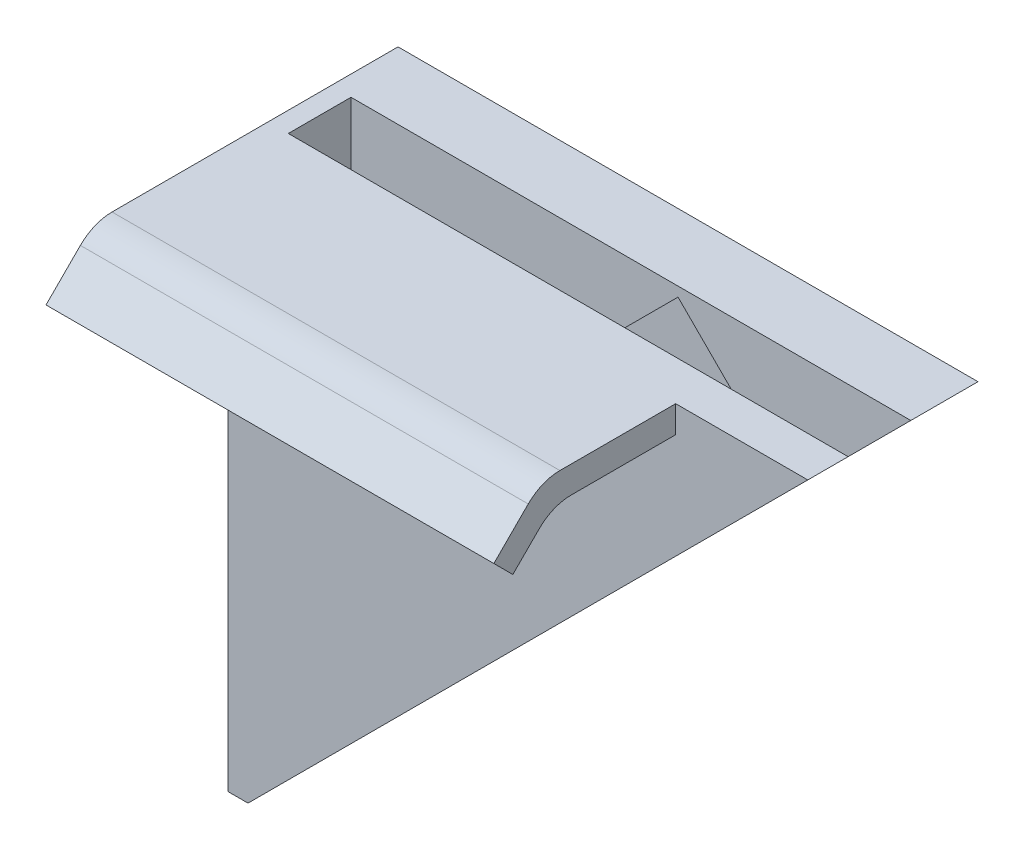
from build123d import *

# Parameters (mm, degrees)
SALIENTE_EXTRUIR1_DEPTH = 1.8
CROQUIS2_W              = 7.6
CROQUIS2_H              = 25
SALIENTE_EXTRUIR2_DEPTH = 0.9
SALIENTE_EXTRUIR3_DEPTH = 3
CORTAR_EXTRUIR1_DEPTH   = 2.05
SALIENTE_EXTRUIR4_DEPTH = 20
REDONDEO1_R             = 2


with BuildPart() as part:
    # Croquis1 → Saliente-Extruir1 (new body)
    with BuildSketch(Plane.XY):
        Polygon((0, 0), (25, 0), (0, -25), align=None)
    extrude(amount=SALIENTE_EXTRUIR1_DEPTH)

    # Croquis2 → Saliente-Extruir2 (add)
    with BuildSketch(Plane.ZY):
        with Locations((-2, -12.5)):
            Rectangle(CROQUIS2_W, CROQUIS2_H)
    extrude(amount=SALIENTE_EXTRUIR2_DEPTH)

    # Croquis3 → Saliente-Extruir3 (add)
    with BuildSketch(Plane(origin=(0, 0, -5.8), x_dir=(-1, 0, 0), z_dir=(0, 0, -1))):
        Polygon((0, 0), (-25, 0), (0, -25), align=None)
    extrude(amount=-SALIENTE_EXTRUIR3_DEPTH)

    # Croquis4 → Cortar-Extruir1 (cut)
    with BuildSketch(Plane.XY.offset(-2.8)):
        Polygon((18.8816387, -4.704147737), (4.704147737, -18.8816387), (0.426151711, -14.603642674), (14.603642674, -0.426151711), align=None)
    extrude(amount=-CORTAR_EXTRUIR1_DEPTH, mode=Mode.SUBTRACT)

    # Croquis5 → Saliente-Extruir4 (add)
    with BuildSketch(Plane.ZY.offset(0.9)):
        Polygon((1.8, 0), (7.8, 0), (9.921320344, -2.121320344), (9.072792206, -2.969848481), (7.302943725, -1.2), (1.8, -1.2), align=None)
    extrude(amount=-SALIENTE_EXTRUIR4_DEPTH)

    # Redondeo1
    redondeo1_edges = [part.edges().sort_by_distance(p)[0] for p in [
        (9.1, 0, 7.8),
        (9.1, -1.2, 7.302943725),
    ]]
    fillet(redondeo1_edges, radius=REDONDEO1_R)


solid = part.part
